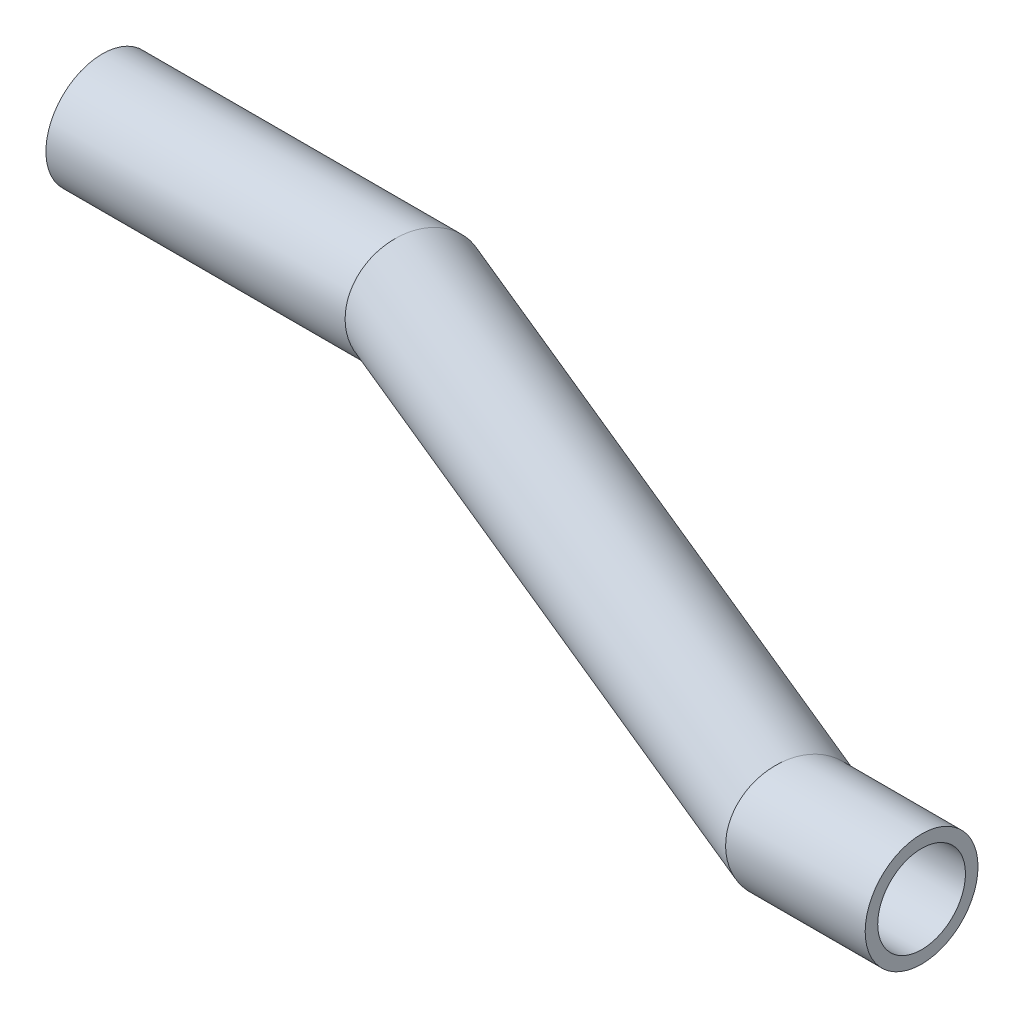
from build123d import *

# Parameters (mm, degrees)
SKETCH2_R   = 4.5
SKETCH2_R_2 = 3.5


with BuildPart() as part:
    # Sweep1: sweep along a curve in space
    with BuildLine() as sweep1_path:
        Line((0, 0, 0), (-25, 0, 0))
        Line((0, 0, 0), (65, 13.43503, 34.64823))
        Line((65, 13.43503, 34.64823), (75, 13.43503, 34.64823))
    # Sketch2 → Sweep1 (sweep)
    with BuildSketch(Plane(origin=(0, 0, 0), x_dir=(0, 0, -1), z_dir=(1, 0, 0))):
        Circle(SKETCH2_R)
        Circle(SKETCH2_R_2, mode=Mode.SUBTRACT)
    sweep(path=sweep1_path.line, transition=Transition.RIGHT)


solid = part.part
